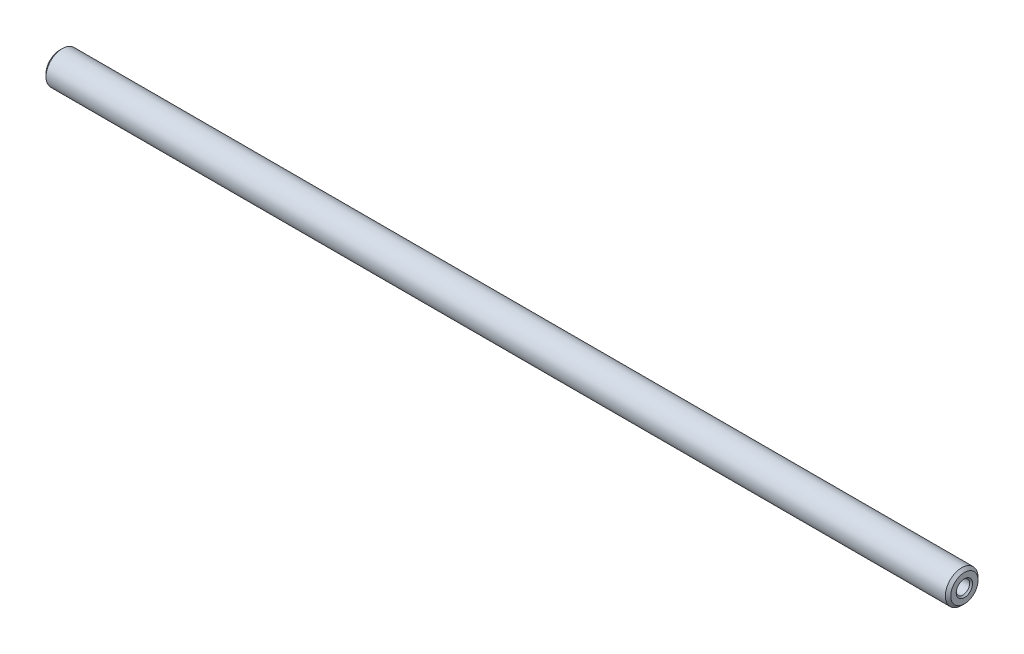
from build123d import *


with BuildPart() as part:
    # Sketch1 → Revolve1 (revolve)
    with BuildSketch(Plane(origin=(0, 0, 0), x_dir=(-1, 0, 0), z_dir=(0, 0, -1))):
        Polygon((-155.209852156, 1.2295), (-154.500000005, 8e-09), (-11.5, 8e-09), (-10.790147844, 1.2295), (-0.2705, 1.2295), (0, 1.5), (0, 2.5), (-0.5, 3), (-165.5, 3), (-166, 2.5), (-166, 1.5), (-165.7295, 1.2295), align=None)
    revolve(axis=Axis((166, 8e-09, 0), (-1, 0, 0)))


solid = part.part
